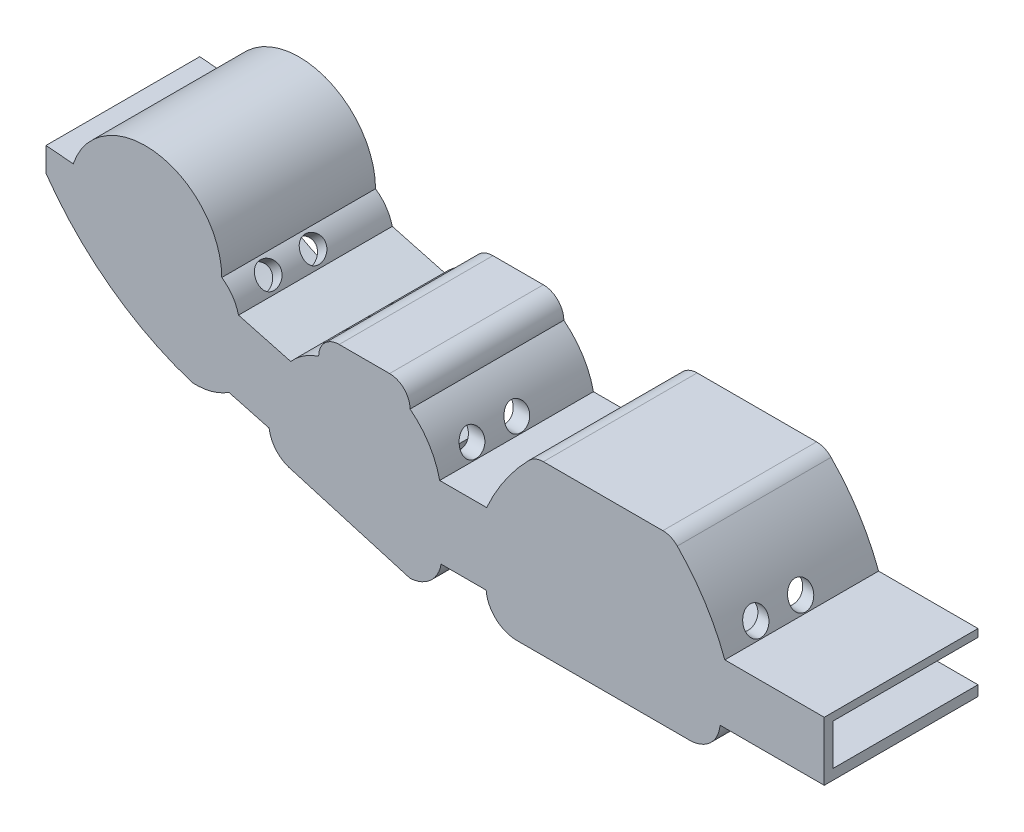
from build123d import *

# Parameters (mm, degrees)
WALLS_DEPTH                         = 16
BASE_DEPTH                          = 1
CUT_EXTRUDE2_REACH                  = 71.681
CUT_EXTRUDE2_END_RADIUS             = 7.978898039
SKETCH14_R                          = 1.4
CUT_EXTRUDE3_REACH                  = 87.792
CUT_EXTRUDE3_END_RADIUS             = 7.978898039
SKETCH15_R                          = 1.4
CUT_EXTRUDE4_REACH                  = 73.058
CUT_EXTRUDE4_END_RADIUS             = 33.443931457
SKETCH16_R                          = 1.4
CUT_EXTRUDE4_DIRECTION_2_REACH      = 73.058
CUT_EXTRUDE4_DIRECTION_2_END_RADIUS = 4.849339701
CUT_EXTRUDE5_REACH                  = 67.913
CUT_EXTRUDE5_END_RADIUS             = 6.135740623
SKETCH18_R                          = 1.4
CUT_EXTRUDE6_DEPTH                  = 1
CUT_EXTRUDE7_START                  = 1
SKETCH20_W                          = 0.5
SKETCH20_H                          = 5.968950485
CUT_EXTRUDE7_DEPTH                  = 13
CUT_EXTRUDE8_REACH                  = 87.792
SKETCH21_W                          = 1.2
SKETCH21_H                          = 4.8
CUT_EXTRUDE8_DIRECTION_2_REACH      = 87.792
BOSS_EXTRUDE7_DEPTH                 = 1


with BuildPart() as part:
    # Sketch1 → Walls (new body)
    with BuildSketch(Plane.XY):
        with BuildLine():
            Line((-2.714226626, -4.104973799), (9.481662569, -4.104973799))
            Line((9.481662569, -4.104973799), (9.481662569, 2.795026201))
            Line((9.481662569, 2.795026201), (-2.157765014, 2.795026201))
            ThreePointArc((-2.157765014, 2.795026201), (-4.475421171, 7.467506564), (-7.720187416, 11.551021571))
            ThreePointArc((-7.720187416, 11.551021571), (-8.494484922, 12.081481284), (-9.414311331, 12.268145448))
            Line((-9.414311331, 12.268145448), (-23.396800773, 12.268145448))
            ThreePointArc((-23.396800773, 12.268145448), (-24.316627182, 12.081481284), (-25.090924688, 11.551021571))
            ThreePointArc((-25.090924688, 11.551021571), (-27.89010211, 8.144207478), (-30.040818273, 4.295026201))
            Line((-30.040818273, 4.295026201), (-35.538103823, 4.295026201))
            ThreePointArc((-35.538103823, 4.295026201), (-36.788812463, 7.352239347), (-39.003987198, 9.802509784))
            ThreePointArc((-39.003987198, 9.802509784), (-39.706930923, 11.499566059), (-41.403987198, 12.202509784))
            Line((-41.403987198, 12.202509784), (-47.303987198, 12.202509784))
            ThreePointArc((-47.303987198, 12.202509784), (-49.001043473, 11.499566059), (-49.703987198, 9.802509784))
            ThreePointArc((-49.703987198, 9.802509784), (-51.484886069, 8.942613092), (-52.972674129, 7.63972791))
            Line((-52.972674129, 7.63972791), (-59.085187578, 9.280115945))
            ThreePointArc((-59.085187578, 9.280115945), (-59.805528448, 10.877592909), (-61.046606478, 12.114746473))
            ThreePointArc((-61.046606478, 12.114746473), (-68.542766302, 20.896236037), (-78.43721729, 14.945873803))
            Line((-78.43721729, 14.945873803), (-81.625677347, 15.217392614))
            Line((-81.625677347, 15.217392614), (-81.625677347, 12.385824824))
            ThreePointArc((-81.625677347, 12.385824824), (-74.106348322, 4.663063574), (-64.521084045, -0.266851135))
            ThreePointArc((-64.521084045, -0.266851135), (-62.274490708, -0.03182968), (-60.209952013, 0.884738205))
            Line((-60.209952013, 0.884738205), (-57.912719989, 0.268240269))
            Line((-57.912719989, 0.268240269), (-55.505171624, -0.377862773))
            ThreePointArc((-55.505171624, -0.377862773), (-54.613521198, -2.28542285), (-52.779036899, -3.319102342))
            Line((-52.779036899, -3.319102342), (-39.012163448, -7.362532125))
            ThreePointArc((-39.012163448, -7.362532125), (-36.623330152, -6.369383775), (-35.372204411, -4.104973799))
            Line((-35.372204411, -4.104973799), (-30.101206151, -4.104973799))
            ThreePointArc((-30.101206151, -4.104973799), (-28.953550113, -6.460513587), (-26.512978021, -7.414080542))
            Line((-26.512978021, -7.414080542), (-6.302454756, -7.414080542))
            ThreePointArc((-6.302454756, -7.414080542), (-3.861882663, -6.460513587), (-2.714226626, -4.104973799))
        make_face()
        with BuildLine():
            Line((-11.180694354, 10.652027), (-11.480694354, 9.152027))
            Line((-11.480694354, 9.152027), (-11.780694354, 10.652027))
            Line((-11.780694354, 10.652027), (-12.480694354, 10.652027))
            Line((-12.480694354, 10.652027), (-12.780694354, 9.152027))
            Line((-12.780694354, 9.152027), (-13.080694354, 10.652027))
            Line((-13.080694354, 10.652027), (-13.754684343, 10.652027))
            Line((-13.754684343, 10.652027), (-14.054684343, 9.152027))
            Line((-14.054684343, 9.152027), (-14.354684343, 10.652027))
            Line((-14.354684343, 10.652027), (-15.054684343, 10.652027))
            Line((-15.054684343, 10.652027), (-15.354684343, 9.152027))
            Line((-15.354684343, 9.152027), (-15.654684343, 10.652027))
            Line((-15.654684343, 10.652027), (-16.354684343, 10.652027))
            Line((-16.354684343, 10.652027), (-16.654684343, 9.152027))
            Line((-16.654684343, 9.152027), (-16.954684343, 10.652027))
            Line((-16.954684343, 10.652027), (-17.654684343, 10.652027))
            Line((-17.654684343, 10.652027), (-17.954684343, 9.152027))
            Line((-17.954684343, 9.152027), (-18.254684343, 10.652027))
            Line((-18.254684343, 10.652027), (-18.954684343, 10.652027))
            Line((-18.954684343, 10.652027), (-19.254684343, 9.152027))
            Line((-19.254684343, 9.152027), (-19.554684343, 10.652027))
            Line((-19.554684343, 10.652027), (-20.254684343, 10.652027))
            Line((-20.254684343, 10.652027), (-20.554684343, 9.152027))
            Line((-20.554684343, 9.152027), (-20.854684343, 10.652027))
            Line((-20.854684343, 10.652027), (-21.554684343, 10.652027))
            Line((-21.554684343, 10.652027), (-21.854684343, 9.152027))
            Line((-21.854684343, 9.152027), (-22.154684343, 10.652027))
            Line((-22.154684343, 10.652027), (-22.854684343, 10.652027))
            Line((-22.854684343, 10.652027), (-23.154684343, 9.152027))
            Line((-23.154684343, 9.152027), (-23.457941673, 10.657707986))
            ThreePointArc((-23.457941673, 10.657707986), (-24.295920105, 10.483827589), (-24.983754411, 9.974586769))
            ThreePointArc((-24.983754411, 9.974586769), (-25.343038743, 9.372290059), (-25.468103034, 8.682213628))
            ThreePointArc((-25.468103034, 8.682213628), (-27.891258334, 6.284887251), (-29.092774814, 3.095026201))
            Line((-29.092774814, 3.095026201), (-37.092774814, 3.095026201))
            ThreePointArc((-37.092774814, 3.095026201), (-38.294291294, 6.284887251), (-40.717446594, 8.682213628))
            ThreePointArc((-40.717446594, 8.682213628), (-41.303233031, 10.096427191), (-42.717446594, 10.682213628))
            Line((-42.717446594, 10.682213628), (-42.859602924, 10.682178618))
            Line((-42.859602924, 10.682178618), (-43.159602924, 9.182178618))
            Line((-43.159602924, 9.182178618), (-43.459602924, 10.682178618))
            Line((-43.459602924, 10.682178618), (-44.133592914, 10.682178618))
            Line((-44.133592914, 10.682178618), (-44.433592914, 9.182178618))
            Line((-44.433592914, 9.182178618), (-44.733592914, 10.682178618))
            Line((-44.733592914, 10.682178618), (-45.433592914, 10.682178618))
            Line((-45.433592914, 10.682178618), (-45.733592914, 9.182178618))
            Line((-45.733592914, 9.182178618), (-46.033592914, 10.682178618))
            Line((-46.033592914, 10.682178618), (-46.733592914, 10.682178618))
            Line((-46.733592914, 10.682178618), (-47.033592914, 9.182178618))
            Line((-47.033592914, 9.182178618), (-47.333592914, 10.682178618))
            Line((-47.333592914, 10.682178618), (-47.417446594, 10.682213628))
            ThreePointArc((-47.417446594, 10.682213628), (-48.831660156, 10.096427191), (-49.417446594, 8.682213628))
            ThreePointArc((-49.417446594, 8.682213628), (-51.203259287, 7.752660176), (-52.592067832, 6.295125468))
            Line((-52.592067832, 6.295125468), (-60.318669602, 8.368679203))
            ThreePointArc((-60.318669602, 8.368679203), (-60.871585206, 9.985898204), (-62.04355905, 11.229920016))
            ThreePointArc((-62.04355905, 11.229920016), (-62.182359005, 13.084494169), (-62.74355905, 14.857560784))
            Line((-62.74355905, 14.857560784), (-63.04355905, 12.857560784))
            Line((-63.04355905, 12.857560784), (-63.34355905, 15.955023014))
            ThreePointArc((-63.34355905, 15.955023014), (-63.676987636, 16.427873033), (-64.04355905, 16.875519278))
            Line((-64.04355905, 16.875519278), (-64.34355905, 15.675519278))
            Line((-64.34355905, 15.675519278), (-64.64355905, 17.487555249))
            ThreePointArc((-64.64355905, 17.487555249), (-64.98549923, 17.783767154), (-65.34355905, 18.060277091))
            Line((-65.34355905, 18.060277091), (-65.64355905, 16.960277091))
            Line((-65.64355905, 16.960277091), (-65.94355905, 18.457409466))
            ThreePointArc((-65.94355905, 18.457409466), (-66.28894338, 18.652985458), (-66.64355905, 18.831277439))
            Line((-66.64355905, 18.831277439), (-66.94355905, 17.831277439))
            Line((-66.94355905, 17.831277439), (-67.24355905, 19.085409669))
            ThreePointArc((-67.24355905, 19.085409669), (-67.590953429, 19.207208521), (-67.94355905, 19.312977563))
            Line((-67.94355905, 19.312977563), (-68.24355905, 18.262977563))
            Line((-68.24355905, 18.262977563), (-68.54355905, 19.453586402))
            ThreePointArc((-68.54355905, 19.453586402), (-68.892411481, 19.513414143), (-69.24355905, 19.557829923))
            Line((-69.24355905, 19.557829923), (-69.54355905, 18.457829923))
            Line((-69.54355905, 18.457829923), (-69.84355905, 19.597729108))
            ThreePointArc((-69.84355905, 19.597729108), (-70.194297473, 19.600247924), (-70.544811991, 19.58746676))
            Line((-70.544811991, 19.58746676), (-70.844811991, 18.396857922))
            Line((-70.844811991, 18.396857922), (-71.144811991, 19.529836442))
            ThreePointArc((-71.144811991, 19.529836442), (-71.495091081, 19.474995797), (-71.8426118, 19.404765549))
            Line((-71.8426118, 19.404765549), (-72.1426118, 18.147652874))
            Line((-72.1426118, 18.147652874), (-72.4426118, 19.245103414))
            ThreePointArc((-72.4426118, 19.245103414), (-72.795255794, 19.127528905), (-73.142088231, 18.993779836))
            Line((-73.142088231, 18.993779836), (-73.442088231, 17.693779836))
            Line((-73.442088231, 17.693779836), (-73.742088231, 18.716947696))
            ThreePointArc((-73.742088231, 18.716947696), (-74.096217932, 18.524190844), (-74.440238881, 18.313922832))
            Line((-74.440238881, 18.313922832), (-74.740238881, 16.813922832))
            Line((-74.740238881, 16.813922832), (-75.040238881, 17.88599014))
            ThreePointArc((-75.040238881, 17.88599014), (-75.400039352, 17.586290744), (-75.741781559, 17.266152694))
            Line((-75.741781559, 17.266152694), (-76.041781559, 15.366152694))
            Line((-76.041781559, 15.366152694), (-76.341781559, 16.599884754))
            ThreePointArc((-76.341781559, 16.599884754), (-77.445352232, 14.777174034), (-78.031367356, 12.728582111))
            ThreePointArc((-78.031367356, 12.728582111), (-78.438180255, 12.562213326), (-78.840750005, 12.385824824))
            Line((-78.840750005, 12.385824824), (-80.49851244, 13.504674103))
            Line((-80.49851244, 13.504674103), (-80.884189776, 13.945331795))
            Line((-80.884189776, 13.945331795), (-80.884189776, 13.209190532))
            Line((-80.884189776, 13.209190532), (-77.58669117, 9.26545403))
            ThreePointArc((-77.58669117, 9.26545403), (-71.880116285, 4.137190402), (-64.962994505, 0.817926775))
            ThreePointArc((-64.962994505, 0.817926775), (-62.911197396, 1.000283853), (-61.460670014, 2.462848653))
            Line((-61.460670014, 2.462848653), (-53.620034751, 0.358692257))
            ThreePointArc((-53.620034751, 0.358692257), (-52.997180114, -1.501489359), (-51.3260009, -2.528807996))
            Line((-51.3260009, -2.528807996), (-40.070273024, -5.898332815))
            ThreePointArc((-40.070273024, -5.898332815), (-38.052537425, -4.937523747), (-37.123477835, -2.904973799))
            Line((-37.123477835, -2.904973799), (-29.097095345, -2.904973799))
            ThreePointArc((-29.097095345, -2.904973799), (-28.326338138, -5.239633694), (-26.069092729, -6.214080542))
            Line((-26.069092729, -6.214080542), (-6.746340048, -6.214080542))
            ThreePointArc((-6.746340048, -6.214080542), (-4.489094638, -5.239633694), (-3.718337431, -2.904973799))
            Line((-3.718337431, -2.904973799), (8.281662569, -2.904973799))
            Line((8.281662569, -2.904973799), (8.281662569, 1.895026201))
            Line((8.281662569, 1.895026201), (-3.634781843, 1.895026201))
            ThreePointArc((-3.634781843, 1.895026201), (-4.611558125, 5.76795929), (-7.34300907, 8.682213628))
            ThreePointArc((-7.34300907, 8.682213628), (-8.12308073, 9.896738229), (-9.353170431, 10.652027))
            Line((-9.353170431, 10.652027), (-9.906704364, 10.652027))
            Line((-9.906704364, 10.652027), (-10.206704364, 9.152027))
            Line((-10.206704364, 9.152027), (-10.506704364, 10.652027))
            Line((-10.506704364, 10.652027), (-11.180694354, 10.652027))
        make_face(mode=Mode.SUBTRACT)
    extrude(amount=WALLS_DEPTH)

    # Sketch2 → Base (add)
    with BuildSketch(Plane(origin=(0, 0, 0), x_dir=(-1, 0, 0), z_dir=(0, 0, -1))):
        with BuildLine():
            Line((59.085187578, 9.280115945), (52.972674129, 7.63972791))
            ThreePointArc((52.972674129, 7.63972791), (51.484886069, 8.942613092), (49.703987198, 9.802509784))
            ThreePointArc((49.703987198, 9.802509784), (49.001043473, 11.499566059), (47.303987198, 12.202509784))
            Line((47.303987198, 12.202509784), (41.403987198, 12.202509784))
            ThreePointArc((41.403987198, 12.202509784), (39.706930923, 11.499566059), (39.003987198, 9.802509784))
            ThreePointArc((39.003987198, 9.802509784), (36.788812463, 7.352239347), (35.538103823, 4.295026201))
            Line((35.538103823, 4.295026201), (30.040818273, 4.295026201))
            ThreePointArc((30.040818273, 4.295026201), (27.89010211, 8.144207478), (25.090924688, 11.551021571))
            ThreePointArc((25.090924688, 11.551021571), (24.316627182, 12.081481284), (23.396800773, 12.268145448))
            Line((23.396800773, 12.268145448), (9.414311331, 12.268145448))
            ThreePointArc((9.414311331, 12.268145448), (8.494484922, 12.081481284), (7.720187416, 11.551021571))
            ThreePointArc((7.720187416, 11.551021571), (4.475421171, 7.467506564), (2.157765014, 2.795026201))
            Line((2.157765014, 2.795026201), (-9.481662569, 2.795026201))
            Line((-9.481662569, 2.795026201), (-9.481662569, -4.104973799))
            Line((-9.481662569, -4.104973799), (2.714226626, -4.104973799))
            ThreePointArc((2.714226626, -4.104973799), (3.861882663, -6.460513587), (6.302454756, -7.414080542))
            Line((6.302454756, -7.414080542), (26.512978021, -7.414080542))
            ThreePointArc((26.512978021, -7.414080542), (28.953550113, -6.460513587), (30.101206151, -4.104973799))
            Line((30.101206151, -4.104973799), (35.372204411, -4.104973799))
            ThreePointArc((35.372204411, -4.104973799), (36.623330152, -6.369383775), (39.012163448, -7.362532125))
            Line((39.012163448, -7.362532125), (52.779036899, -3.319102342))
            ThreePointArc((52.779036899, -3.319102342), (54.613521198, -2.28542285), (55.505171624, -0.377862773))
            Line((55.505171624, -0.377862773), (60.209952013, 0.884738205))
            ThreePointArc((60.209952013, 0.884738205), (62.274490708, -0.03182968), (64.521084045, -0.266851135))
            ThreePointArc((64.521084045, -0.266851135), (74.106348322, 4.663063574), (81.625677347, 12.385824824))
            Line((81.625677347, 12.385824824), (81.625677347, 15.217392614))
            Line((81.625677347, 15.217392614), (78.43721729, 14.945873803))
            ThreePointArc((78.43721729, 14.945873803), (68.542766302, 20.896236037), (61.046606478, 12.114746473))
            ThreePointArc((61.046606478, 12.114746473), (59.805528448, 10.877592909), (59.085187578, 9.280115945))
        make_face()
    extrude(amount=BASE_DEPTH)

    # Cut-Extrude2: up to this cylinder (the profile starts outside it)
    cut_extrude2_end = Plane(origin=(-21.197572731, 1.942377959, 10.125), z_dir=(0, 0, -1)) * Cylinder(CUT_EXTRUDE2_END_RADIUS, 165.569796077, mode=Mode.PRIVATE)
    # Sketch14 → Cut-Extrude2 (cut, up to the surface)
    with BuildSketch(Plane(origin=(-55, 0, 0), x_dir=(0, 0, -1), z_dir=(1, 0, 0)), mode=Mode.PRIVATE) as cut_extrude2_sk1:
        with Locations(Location((-12.75, 5.771124661, 0), (0, 0, 180))):
            Circle(SKETCH14_R)
    cut_extrude2_tool1 = extrude(cut_extrude2_sk1.sketch, amount=CUT_EXTRUDE2_REACH, mode=Mode.PRIVATE) - cut_extrude2_end
    add(cut_extrude2_tool1.solids().sort_by_distance((-55, 5.771125, 12.75))[0], mode=Mode.SUBTRACT)
    # Sketch14 → Cut-Extrude2 (cut, up to the surface)
    with BuildSketch(Plane(origin=(-55, 0, 0), x_dir=(0, 0, -1), z_dir=(1, 0, 0)), mode=Mode.PRIVATE) as cut_extrude2_sk2:
        with Locations(Location((-7.5, 5.771124661, 0), (0, 0, 180))):
            Circle(SKETCH14_R)
    cut_extrude2_tool2 = extrude(cut_extrude2_sk2.sketch, amount=CUT_EXTRUDE2_REACH, mode=Mode.PRIVATE) - cut_extrude2_end
    add(cut_extrude2_tool2.solids().sort_by_distance((-55, 5.771125, 7.5))[0], mode=Mode.SUBTRACT)

    # Cut-Extrude3: up to this cylinder (the profile starts outside it)
    cut_extrude3_end = Plane(origin=(-11.613539373, 1.942377959, 10.125), z_dir=(0, 0, -1)) * Cylinder(CUT_EXTRUDE3_END_RADIUS, 197.791796077, mode=Mode.PRIVATE)
    # Sketch15 → Cut-Extrude3 (cut, up to the surface)
    with BuildSketch(Plane(origin=(0, 0, 0), x_dir=(0, 0, -1), z_dir=(1, 0, 0)), mode=Mode.PRIVATE) as cut_extrude3_sk1:
        with Locations((-12.75, 4.295026201)):
            Circle(SKETCH15_R)
    cut_extrude3_tool1 = extrude(cut_extrude3_sk1.sketch, amount=-CUT_EXTRUDE3_REACH, mode=Mode.PRIVATE) - cut_extrude3_end
    add(cut_extrude3_tool1.solids().sort_by_distance((0, 4.295026, 12.75))[0], mode=Mode.SUBTRACT)
    # Sketch15 → Cut-Extrude3 (cut, up to the surface)
    with BuildSketch(Plane(origin=(0, 0, 0), x_dir=(0, 0, -1), z_dir=(1, 0, 0)), mode=Mode.PRIVATE) as cut_extrude3_sk2:
        with Locations((-7.5, 4.295026201)):
            Circle(SKETCH15_R)
    cut_extrude3_tool2 = extrude(cut_extrude3_sk2.sketch, amount=-CUT_EXTRUDE3_REACH, mode=Mode.PRIVATE) - cut_extrude3_end
    add(cut_extrude3_tool2.solids().sort_by_distance((0, 4.295026, 7.5))[0], mode=Mode.SUBTRACT)

    # Cut-Extrude4: up to this cylinder (the profile starts inside it)
    cut_extrude4_end = Plane(origin=(-54.217257268, 31.550246549, 10.125), z_dir=(0, 0, -1)) * Cylinder(CUT_EXTRUDE4_END_RADIUS, 219.253862914, mode=Mode.PRIVATE)
    # Sketch16 → Cut-Extrude4 (cut, up to the surface)
    with BuildSketch(Plane(origin=(-30.126273658, -25.259010635, 0), x_dir=(0, 0, -1), z_dir=(0.7662940611199272, 0.6424900091770529, 0)), mode=Mode.PRIVATE) as cut_extrude4_sk1:
        with Locations(Location((-12.75, 46.789116738, 0), (0, 0, 90))):
            Circle(SKETCH16_R)
    cut_extrude4_tool1 = extrude(cut_extrude4_sk1.sketch, amount=-CUT_EXTRUDE4_REACH, mode=Mode.PRIVATE) & cut_extrude4_end
    add(cut_extrude4_tool1.solids().sort_by_distance((-60.187814, 10.595212, 12.75))[0], mode=Mode.SUBTRACT)
    # Sketch16 → Cut-Extrude4 (cut, up to the surface)
    with BuildSketch(Plane(origin=(-30.126273658, -25.259010635, 0), x_dir=(0, 0, -1), z_dir=(0.7662940611199272, 0.6424900091770529, 0)), mode=Mode.PRIVATE) as cut_extrude4_sk2:
        with Locations(Location((-7.5, 46.789116738, 0), (0, 0, 90))):
            Circle(SKETCH16_R)
    cut_extrude4_tool2 = extrude(cut_extrude4_sk2.sketch, amount=-CUT_EXTRUDE4_REACH, mode=Mode.PRIVATE) & cut_extrude4_end
    add(cut_extrude4_tool2.solids().sort_by_distance((-60.187814, 10.595212, 7.5))[0], mode=Mode.SUBTRACT)

    # Cut-Extrude4 direction 2: up to this cylinder (the profile starts inside it)
    cut_extrude4_direction_2_end = Plane(origin=(-63.79328755, 8.118268196, 10.125), z_dir=(0, 0, -1)) * Cylinder(CUT_EXTRUDE4_DIRECTION_2_END_RADIUS, 162.064679402, mode=Mode.PRIVATE)
    # Sketch16 → Cut-Extrude4 direction 2 (cut, up to the surface)
    with BuildSketch(Plane(origin=(-30.126273658, -25.259010635, 0), x_dir=(0, 0, -1), z_dir=(0.7662940611199272, 0.6424900091770529, 0)), mode=Mode.PRIVATE) as cut_extrude4_direction_2_sk1:
        with Locations(Location((-12.75, 46.789116738, 0), (0, 0, 90))):
            Circle(SKETCH16_R)
    cut_extrude4_direction_2_tool1 = extrude(cut_extrude4_direction_2_sk1.sketch, amount=CUT_EXTRUDE4_DIRECTION_2_REACH, mode=Mode.PRIVATE) & cut_extrude4_direction_2_end
    add(cut_extrude4_direction_2_tool1.solids().sort_by_distance((-60.187814, 10.595212, 12.75))[0], mode=Mode.SUBTRACT)
    # Sketch16 → Cut-Extrude4 direction 2 (cut, up to the surface)
    with BuildSketch(Plane(origin=(-30.126273658, -25.259010635, 0), x_dir=(0, 0, -1), z_dir=(0.7662940611199272, 0.6424900091770529, 0)), mode=Mode.PRIVATE) as cut_extrude4_direction_2_sk2:
        with Locations(Location((-7.5, 46.789116738, 0), (0, 0, 90))):
            Circle(SKETCH16_R)
    cut_extrude4_direction_2_tool2 = extrude(cut_extrude4_direction_2_sk2.sketch, amount=CUT_EXTRUDE4_DIRECTION_2_REACH, mode=Mode.PRIVATE) & cut_extrude4_direction_2_end
    add(cut_extrude4_direction_2_tool2.solids().sort_by_distance((-60.187814, 10.595212, 7.5))[0], mode=Mode.SUBTRACT)

    # Cut-Extrude5: up to this cylinder (the profile starts outside it)
    cut_extrude5_end = Plane(origin=(-47.515764964, 2.84861097, 10.125), z_dir=(0, 0, -1)) * Cylinder(CUT_EXTRUDE5_END_RADIUS, 154.347481246, mode=Mode.PRIVATE)
    # Sketch18 → Cut-Extrude5 (cut, up to the surface)
    with BuildSketch(Plane(origin=(-49.220449972, 17.936433015, 0), x_dir=(0, 0, -1), z_dir=(-0.9395597001849877, 0.342385119110478, 0)), mode=Mode.PRIVATE) as cut_extrude5_sk1:
        with Locations(Location((-12.75, 9.38346865, 0), (0, 0, 90))):
            Circle(SKETCH18_R)
    cut_extrude5_tool1 = extrude(cut_extrude5_sk1.sketch, amount=-CUT_EXTRUDE5_REACH, mode=Mode.PRIVATE) - cut_extrude5_end
    add(cut_extrude5_tool1.solids().sort_by_distance((-52.43321, 9.120104, 12.75))[0], mode=Mode.SUBTRACT)
    # Sketch18 → Cut-Extrude5 (cut, up to the surface)
    with BuildSketch(Plane(origin=(-49.220449972, 17.936433015, 0), x_dir=(0, 0, -1), z_dir=(-0.9395597001849877, 0.342385119110478, 0)), mode=Mode.PRIVATE) as cut_extrude5_sk2:
        with Locations(Location((-7.5, 9.38346865, 0), (0, 0, 90))):
            Circle(SKETCH18_R)
    cut_extrude5_tool2 = extrude(cut_extrude5_sk2.sketch, amount=-CUT_EXTRUDE5_REACH, mode=Mode.PRIVATE) - cut_extrude5_end
    add(cut_extrude5_tool2.solids().sort_by_distance((-52.43321, 9.120104, 7.5))[0], mode=Mode.SUBTRACT)

    # Sketch19 → Cut-Extrude6 (cut)
    with BuildSketch(Plane.XY):
        with BuildLine():
            Line((-11.180694354, 10.652027), (-11.480694354, 9.152027))
            Line((-11.480694354, 9.152027), (-11.780694354, 10.652027))
            Line((-11.780694354, 10.652027), (-12.480694354, 10.652027))
            Line((-12.480694354, 10.652027), (-12.780694354, 9.152027))
            Line((-12.780694354, 9.152027), (-13.080694354, 10.652027))
            Line((-13.080694354, 10.652027), (-13.754684343, 10.652027))
            Line((-13.754684343, 10.652027), (-14.054684343, 9.152027))
            Line((-14.054684343, 9.152027), (-14.354684343, 10.652027))
            Line((-14.354684343, 10.652027), (-15.054684343, 10.652027))
            Line((-15.054684343, 10.652027), (-15.354684343, 9.152027))
            Line((-15.354684343, 9.152027), (-15.654684343, 10.652027))
            Line((-15.654684343, 10.652027), (-16.354684343, 10.652027))
            Line((-16.354684343, 10.652027), (-16.654684343, 9.152027))
            Line((-16.654684343, 9.152027), (-16.954684343, 10.652027))
            Line((-16.954684343, 10.652027), (-17.654684343, 10.652027))
            Line((-17.654684343, 10.652027), (-17.954684343, 9.152027))
            Line((-17.954684343, 9.152027), (-18.254684343, 10.652027))
            Line((-18.254684343, 10.652027), (-18.954684343, 10.652027))
            Line((-18.954684343, 10.652027), (-19.254684343, 9.152027))
            Line((-19.254684343, 9.152027), (-19.554684343, 10.652027))
            Line((-19.554684343, 10.652027), (-20.254684343, 10.652027))
            Line((-20.254684343, 10.652027), (-20.554684343, 9.152027))
            Line((-20.554684343, 9.152027), (-20.854684343, 10.652027))
            Line((-20.854684343, 10.652027), (-21.554684343, 10.652027))
            Line((-21.554684343, 10.652027), (-21.854684343, 9.152027))
            Line((-21.854684343, 9.152027), (-22.154684343, 10.652027))
            Line((-22.154684343, 10.652027), (-22.854684343, 10.652027))
            Line((-22.854684343, 10.652027), (-23.154684343, 9.152027))
            Line((-23.154684343, 9.152027), (-23.457941673, 10.657707986))
            ThreePointArc((-23.457941673, 10.657707986), (-24.295920105, 10.483827589), (-24.983754411, 9.974586769))
            ThreePointArc((-24.983754411, 9.974586769), (-25.343038743, 9.372290059), (-25.468103034, 8.682213628))
            ThreePointArc((-25.468103034, 8.682213628), (-27.891258334, 6.284887251), (-29.092774814, 3.095026201))
            Line((-29.092774814, 3.095026201), (-37.092774814, 3.095026201))
            ThreePointArc((-37.092774814, 3.095026201), (-38.294291294, 6.284887251), (-40.717446594, 8.682213628))
            ThreePointArc((-40.717446594, 8.682213628), (-41.303233031, 10.096427191), (-42.717446594, 10.682213628))
            Line((-42.717446594, 10.682213628), (-42.859602924, 10.682178618))
            Line((-42.859602924, 10.682178618), (-43.159602924, 9.182178618))
            Line((-43.159602924, 9.182178618), (-43.459602924, 10.682178618))
            Line((-43.459602924, 10.682178618), (-44.133592914, 10.682178618))
            Line((-44.133592914, 10.682178618), (-44.433592914, 9.182178618))
            Line((-44.433592914, 9.182178618), (-44.733592914, 10.682178618))
            Line((-44.733592914, 10.682178618), (-45.433592914, 10.682178618))
            Line((-45.433592914, 10.682178618), (-45.733592914, 9.182178618))
            Line((-45.733592914, 9.182178618), (-46.033592914, 10.682178618))
            Line((-46.033592914, 10.682178618), (-46.733592914, 10.682178618))
            Line((-46.733592914, 10.682178618), (-47.033592914, 9.182178618))
            Line((-47.033592914, 9.182178618), (-47.333592914, 10.682178618))
            Line((-47.333592914, 10.682178618), (-47.417446594, 10.682213628))
            ThreePointArc((-47.417446594, 10.682213628), (-48.831660156, 10.096427191), (-49.417446594, 8.682213628))
            ThreePointArc((-49.417446594, 8.682213628), (-51.203259287, 7.752660176), (-52.592067832, 6.295125468))
            Line((-52.592067832, 6.295125468), (-60.318669602, 8.368679203))
            ThreePointArc((-60.318669602, 8.368679203), (-60.871585206, 9.985898204), (-62.04355905, 11.229920016))
            ThreePointArc((-62.04355905, 11.229920016), (-62.182359005, 13.084494169), (-62.74355905, 14.857560784))
            Line((-62.74355905, 14.857560784), (-63.04355905, 12.857560784))
            Line((-63.04355905, 12.857560784), (-63.34355905, 15.955023014))
            ThreePointArc((-63.34355905, 15.955023014), (-63.676987636, 16.427873033), (-64.04355905, 16.875519278))
            Line((-64.04355905, 16.875519278), (-64.34355905, 15.675519278))
            Line((-64.34355905, 15.675519278), (-64.64355905, 17.487555249))
            ThreePointArc((-64.64355905, 17.487555249), (-64.98549923, 17.783767154), (-65.34355905, 18.060277091))
            Line((-65.34355905, 18.060277091), (-65.64355905, 16.960277091))
            Line((-65.64355905, 16.960277091), (-65.94355905, 18.457409466))
            ThreePointArc((-65.94355905, 18.457409466), (-66.28894338, 18.652985458), (-66.64355905, 18.831277439))
            Line((-66.64355905, 18.831277439), (-66.94355905, 17.831277439))
            Line((-66.94355905, 17.831277439), (-67.24355905, 19.085409669))
            ThreePointArc((-67.24355905, 19.085409669), (-67.590953429, 19.207208521), (-67.94355905, 19.312977563))
            Line((-67.94355905, 19.312977563), (-68.24355905, 18.262977563))
            Line((-68.24355905, 18.262977563), (-68.54355905, 19.453586402))
            ThreePointArc((-68.54355905, 19.453586402), (-68.892411481, 19.513414143), (-69.24355905, 19.557829923))
            Line((-69.24355905, 19.557829923), (-69.54355905, 18.457829923))
            Line((-69.54355905, 18.457829923), (-69.84355905, 19.597729108))
            ThreePointArc((-69.84355905, 19.597729108), (-70.194297473, 19.600247924), (-70.544811991, 19.58746676))
            Line((-70.544811991, 19.58746676), (-70.844811991, 18.396857922))
            Line((-70.844811991, 18.396857922), (-71.144811991, 19.529836442))
            ThreePointArc((-71.144811991, 19.529836442), (-71.495091081, 19.474995797), (-71.8426118, 19.404765549))
            Line((-71.8426118, 19.404765549), (-72.1426118, 18.147652874))
            Line((-72.1426118, 18.147652874), (-72.4426118, 19.245103414))
            ThreePointArc((-72.4426118, 19.245103414), (-72.795255794, 19.127528905), (-73.142088231, 18.993779836))
            Line((-73.142088231, 18.993779836), (-73.442088231, 17.693779836))
            Line((-73.442088231, 17.693779836), (-73.742088231, 18.716947696))
            ThreePointArc((-73.742088231, 18.716947696), (-74.096217932, 18.524190844), (-74.440238881, 18.313922832))
            Line((-74.440238881, 18.313922832), (-74.740238881, 16.813922832))
            Line((-74.740238881, 16.813922832), (-75.040238881, 17.88599014))
            ThreePointArc((-75.040238881, 17.88599014), (-75.400039352, 17.586290744), (-75.741781559, 17.266152694))
            Line((-75.741781559, 17.266152694), (-76.041781559, 15.366152694))
            Line((-76.041781559, 15.366152694), (-76.341781559, 16.599884754))
            ThreePointArc((-76.341781559, 16.599884754), (-77.445352232, 14.777174034), (-78.031367356, 12.728582111))
            ThreePointArc((-78.031367356, 12.728582111), (-78.438180255, 12.562213326), (-78.840750005, 12.385824824))
            Line((-78.840750005, 12.385824824), (-80.49851244, 13.504674103))
            Line((-80.49851244, 13.504674103), (-80.884189776, 13.945331795))
            Line((-80.884189776, 13.945331795), (-80.884189776, 13.209190532))
            Line((-80.884189776, 13.209190532), (-77.58669117, 9.26545403))
            ThreePointArc((-77.58669117, 9.26545403), (-71.880116285, 4.137190402), (-64.962994505, 0.817926775))
            ThreePointArc((-64.962994505, 0.817926775), (-62.911197396, 1.000283853), (-61.460670014, 2.462848653))
            Line((-61.460670014, 2.462848653), (-53.620034751, 0.358692257))
            ThreePointArc((-53.620034751, 0.358692257), (-52.997180114, -1.501489359), (-51.3260009, -2.528807996))
            Line((-51.3260009, -2.528807996), (-40.070273024, -5.898332815))
            ThreePointArc((-40.070273024, -5.898332815), (-38.052537425, -4.937523747), (-37.123477835, -2.904973799))
            Line((-37.123477835, -2.904973799), (-29.097095345, -2.904973799))
            ThreePointArc((-29.097095345, -2.904973799), (-28.326338138, -5.239633694), (-26.069092729, -6.214080542))
            Line((-26.069092729, -6.214080542), (-6.746340048, -6.214080542))
            ThreePointArc((-6.746340048, -6.214080542), (-4.489094638, -5.239633694), (-3.718337431, -2.904973799))
            Line((-3.718337431, -2.904973799), (8.281662569, -2.904973799))
            Line((8.281662569, -2.904973799), (8.281662569, 1.895026201))
            Line((8.281662569, 1.895026201), (-3.634781843, 1.895026201))
            ThreePointArc((-3.634781843, 1.895026201), (-4.611558125, 5.76795929), (-7.34300907, 8.682213628))
            ThreePointArc((-7.34300907, 8.682213628), (-8.12308073, 9.896738229), (-9.353170431, 10.652027))
            Line((-9.353170431, 10.652027), (-9.906704364, 10.652027))
            Line((-9.906704364, 10.652027), (-10.206704364, 9.152027))
            Line((-10.206704364, 9.152027), (-10.506704364, 10.652027))
            Line((-10.506704364, 10.652027), (-11.180694354, 10.652027))
        make_face()
    extrude(amount=-CUT_EXTRUDE6_DEPTH, mode=Mode.SUBTRACT)

    # Sketch20 → Cut-Extrude7 (cut)
    with BuildSketch(Plane.XY.offset(CUT_EXTRUDE7_START)):
        Polygon((-78.679271747, 6.011586265), (-76.200305026, 8.428703375), (-75.866034878, 8.05629214), (-78.330212458, 5.653595186), align=None)
        Polygon((-47.022644285, -6.255905242), (-45.935109349, -2.203466562), (-45.452196738, -2.333063671), (-46.539731674, -6.385502351), align=None)
        Polygon((-66.95878615, 2.18354453), (-67.990367789, -0.551879915), (-67.522529992, -0.728310627), (-66.490948353, 2.007113819), align=None)
        with Locations((-16.417467247, -6.356352563)):
            Rectangle(SKETCH20_W, SKETCH20_H)
    extrude(amount=CUT_EXTRUDE7_DEPTH, mode=Mode.SUBTRACT)

    # Cut-Extrude8: up to this face of the body (flat: up to its plane)
    cut_extrude8_end = Plane(part.part.faces().sort_by_distance((-36.82767859, 4.90591005, -1))[0])
    # Sketch21 → Cut-Extrude8 (cut, up to the picked face)
    with BuildSketch(Plane.XY, mode=Mode.PRIVATE) as cut_extrude8_sk1:
        with Locations((8.881662569, -0.504973799)):
            Rectangle(SKETCH21_W, SKETCH21_H)
    cut_extrude8_tool1 = split(extrude(cut_extrude8_sk1.sketch, amount=-CUT_EXTRUDE8_REACH, mode=Mode.PRIVATE), bisect_by=cut_extrude8_end, keep=Keep.BOTH, mode=Mode.PRIVATE)
    add(cut_extrude8_tool1.solids().sort_by(Axis((8.881663, -0.504974, 0), (0, 0, -1)))[0], mode=Mode.SUBTRACT)

    # Cut-Extrude8 direction 2: up to this face of the body (flat: up to its plane)
    cut_extrude8_direction_2_end = Plane(part.part.faces().sort_by_distance((-36.82767859, 4.90591005, 16))[0])
    # Sketch21 → Cut-Extrude8 direction 2 (cut, up to the picked face)
    with BuildSketch(Plane.XY, mode=Mode.PRIVATE) as cut_extrude8_direction_2_sk1:
        with Locations((8.881662569, -0.504973799)):
            Rectangle(SKETCH21_W, SKETCH21_H)
    cut_extrude8_direction_2_tool1 = split(extrude(cut_extrude8_direction_2_sk1.sketch, amount=CUT_EXTRUDE8_DIRECTION_2_REACH, mode=Mode.PRIVATE), bisect_by=cut_extrude8_direction_2_end, keep=Keep.BOTH, mode=Mode.PRIVATE)
    add(cut_extrude8_direction_2_tool1.solids().sort_by(Axis((8.881663, -0.504974, 0), (0, 0, 1)))[0], mode=Mode.SUBTRACT)

    # Sketch22 → Boss-Extrude7 (add)
    with BuildSketch(Plane.XY.offset(16)):
        with BuildLine():
            Line((-2.714226626, -4.104973799), (9.481662569, -4.104973799))
            Line((9.481662569, -4.104973799), (9.481662569, 2.795026201))
            Line((9.481662569, 2.795026201), (-2.157765014, 2.795026201))
            ThreePointArc((-2.157765014, 2.795026201), (-4.475421171, 7.467506564), (-7.720187416, 11.551021571))
            ThreePointArc((-7.720187416, 11.551021571), (-8.494484922, 12.081481284), (-9.414311331, 12.268145448))
            Line((-9.414311331, 12.268145448), (-23.396800773, 12.268145448))
            ThreePointArc((-23.396800773, 12.268145448), (-24.316627182, 12.081481284), (-25.090924688, 11.551021571))
            ThreePointArc((-25.090924688, 11.551021571), (-27.89010211, 8.144207478), (-30.040818273, 4.295026201))
            Line((-30.040818273, 4.295026201), (-35.538103823, 4.295026201))
            ThreePointArc((-35.538103823, 4.295026201), (-36.788812463, 7.352239347), (-39.003987198, 9.802509784))
            ThreePointArc((-39.003987198, 9.802509784), (-39.706930923, 11.499566059), (-41.403987198, 12.202509784))
            Line((-41.403987198, 12.202509784), (-47.303987198, 12.202509784))
            ThreePointArc((-47.303987198, 12.202509784), (-49.001043473, 11.499566059), (-49.703987198, 9.802509784))
            ThreePointArc((-49.703987198, 9.802509784), (-51.484886069, 8.942613092), (-52.972674129, 7.63972791))
            Line((-52.972674129, 7.63972791), (-59.085187578, 9.280115945))
            ThreePointArc((-59.085187578, 9.280115945), (-59.805528448, 10.877592909), (-61.046606478, 12.114746473))
            ThreePointArc((-61.046606478, 12.114746473), (-68.542766302, 20.896236037), (-78.43721729, 14.945873803))
            Line((-78.43721729, 14.945873803), (-81.625677347, 15.217392614))
            Line((-81.625677347, 15.217392614), (-81.625677347, 12.385824824))
            ThreePointArc((-81.625677347, 12.385824824), (-74.106348322, 4.663063574), (-64.521084045, -0.266851135))
            ThreePointArc((-64.521084045, -0.266851135), (-62.274490708, -0.03182968), (-60.209952013, 0.884738205))
            Line((-60.209952013, 0.884738205), (-57.912719989, 0.268240269))
            Line((-57.912719989, 0.268240269), (-55.505171624, -0.377862773))
            ThreePointArc((-55.505171624, -0.377862773), (-54.613521198, -2.28542285), (-52.779036899, -3.319102342))
            Line((-52.779036899, -3.319102342), (-39.012163448, -7.362532125))
            ThreePointArc((-39.012163448, -7.362532125), (-36.623330152, -6.369383775), (-35.372204411, -4.104973799))
            Line((-35.372204411, -4.104973799), (-30.101206151, -4.104973799))
            ThreePointArc((-30.101206151, -4.104973799), (-28.953550113, -6.460513587), (-26.512978021, -7.414080542))
            Line((-26.512978021, -7.414080542), (-6.302454756, -7.414080542))
            ThreePointArc((-6.302454756, -7.414080542), (-3.861882663, -6.460513587), (-2.714226626, -4.104973799))
        make_face()
    extrude(amount=BOSS_EXTRUDE7_DEPTH)


solid = part.part
